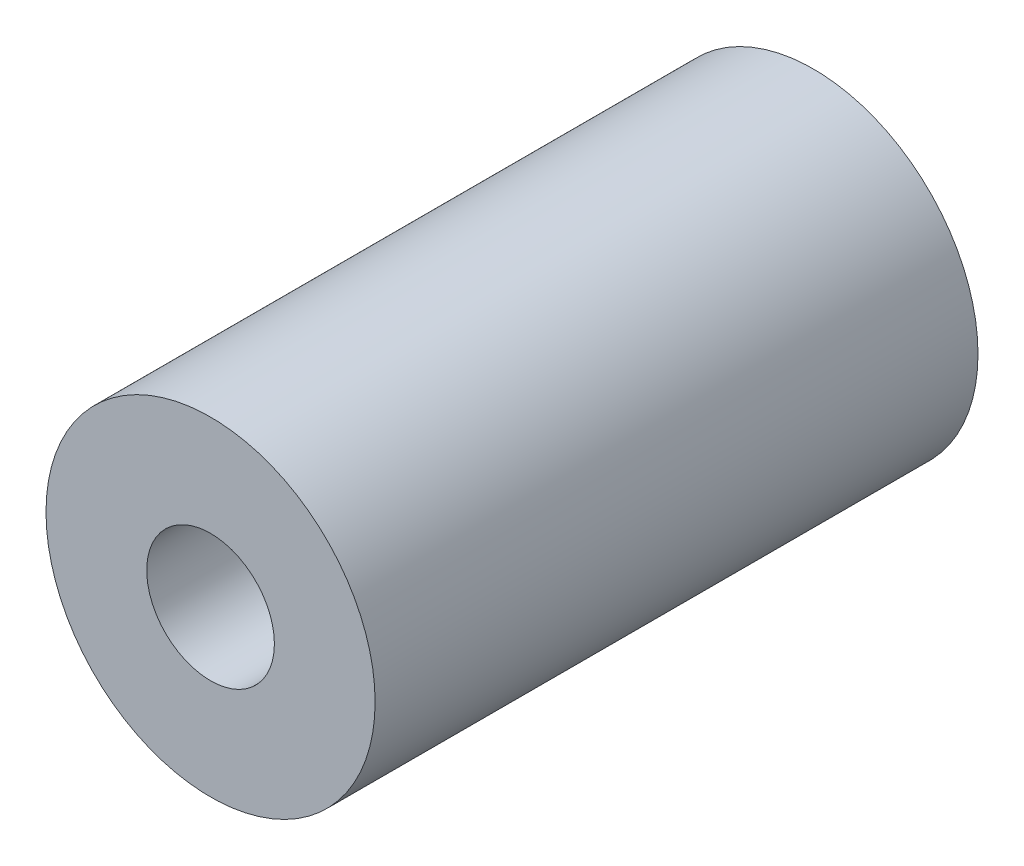
from build123d import *

# Parameters (mm, degrees)
CROQUIS1_R              = 23.2
CROQUIS1_R_2            = 9
SALIENTE_EXTRUIR1_DEPTH = 85


with BuildPart() as part:
    # Croquis1 → Saliente-Extruir1 (new body)
    with BuildSketch(Plane.XY):
        Circle(CROQUIS1_R)
        Circle(CROQUIS1_R_2, mode=Mode.SUBTRACT)
    extrude(amount=SALIENTE_EXTRUIR1_DEPTH)


solid = part.part
